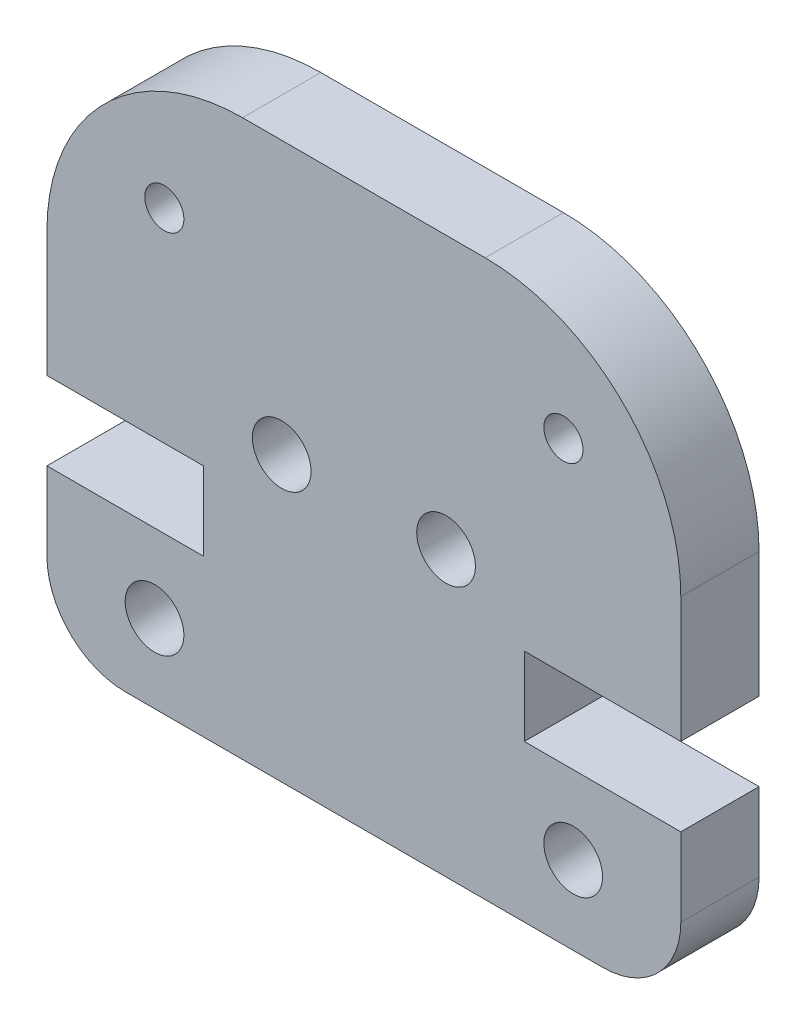
from build123d import *

# Parameters (mm, degrees)
SKETCH1_R           = 0.75
SKETCH1_R_2         = 0.5
BOSS_EXTRUDE1_DEPTH = 2


with BuildPart() as part:
    # Sketch1 → Boss-Extrude1 (new body)
    with BuildSketch(Plane.XY):
        with BuildLine():
            Line((12.2, 4), (16.2, 4))
            Line((16.2, 4), (16.2, 2))
            ThreePointArc((16.2, 2), (15.614213562, 0.585786438), (14.2, 0))
            Line((14.2, 0), (2, 0))
            ThreePointArc((2, 0), (0.585786438, 0.585786438), (0, 2))
            Line((0, 2), (0, 4))
            Line((0, 4), (4, 4))
            Line((4, 4), (4, 6))
            Line((4, 6), (0, 6))
            Line((0, 6), (0, 9.205))
            ThreePointArc((0, 9.205), (1.464466094, 12.740533906), (5, 14.205))
            Line((5, 14.205), (11.2, 14.205))
            ThreePointArc((11.2, 14.205), (14.735533906, 12.740533906), (16.2, 9.205))
            Line((16.2, 9.205), (16.2, 6))
            Line((16.2, 6), (12.2, 6))
            Line((12.2, 6), (12.2, 4))
        make_face()
        with Locations((13.45, 2)):
            Circle(SKETCH1_R, mode=Mode.SUBTRACT)
        with Locations((13.2, 11.205)):
            Circle(SKETCH1_R_2, mode=Mode.SUBTRACT)
        with Locations((10.2, 7.25)):
            Circle(SKETCH1_R, mode=Mode.SUBTRACT)
        with Locations((6, 7.25)):
            Circle(SKETCH1_R, mode=Mode.SUBTRACT)
        with Locations((3, 11.205)):
            Circle(SKETCH1_R_2, mode=Mode.SUBTRACT)
        with Locations((2.75, 2)):
            Circle(SKETCH1_R, mode=Mode.SUBTRACT)
    extrude(amount=BOSS_EXTRUDE1_DEPTH)


solid = part.part
